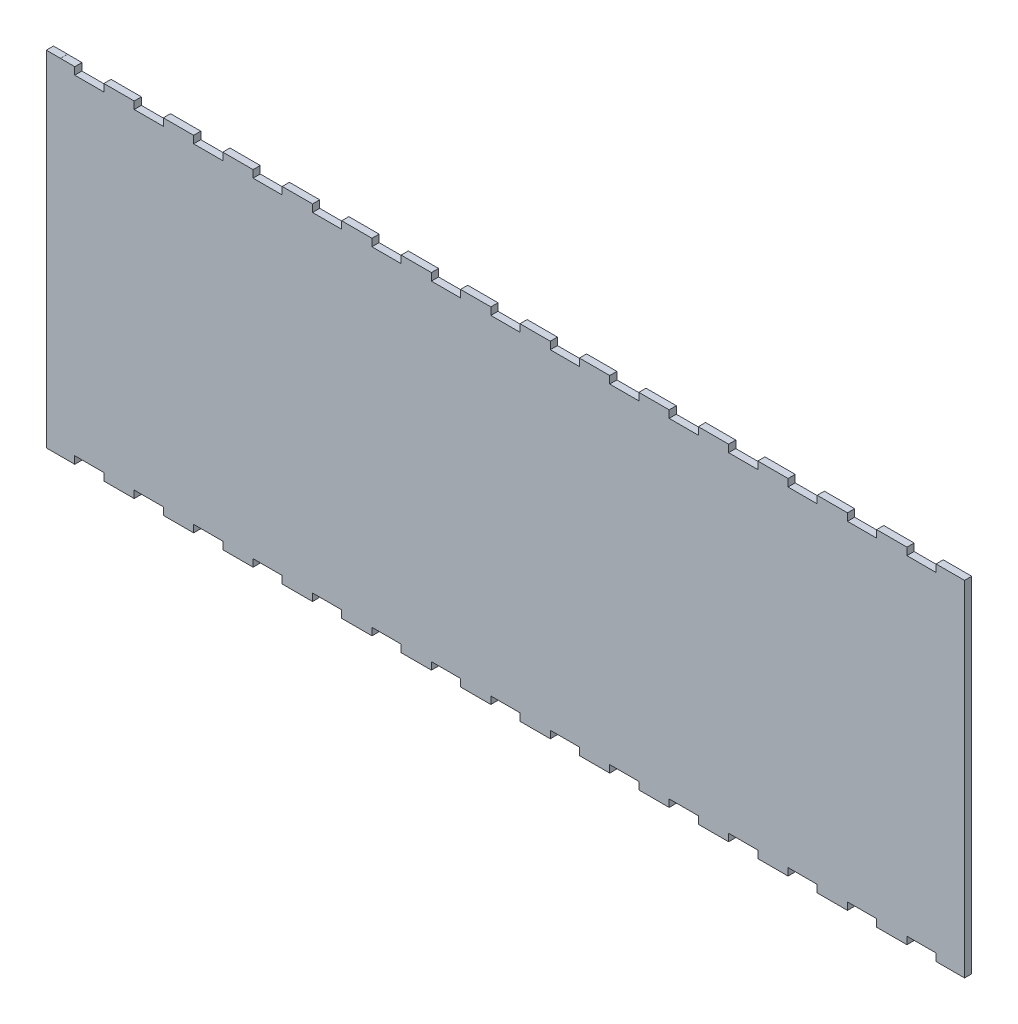
from build123d import *

# Parameters (mm, degrees)
BOSS_EXTRUDE2_DEPTH = 3.175


with BuildPart() as part:
    # Sketch1 → Boss-Extrude2 (new body)
    with BuildSketch(Plane.XY):
        Polygon((393.8, 152.4), (393.8, 149.125), (380.9, 149.125), (380.9, 152.4), (367.492857143, 152.4), (367.492857143, 149.125), (354.592857143, 149.125), (354.592857143, 152.4), (341.185714286, 152.4), (341.185714286, 149.125), (328.285714286, 149.125), (328.285714286, 152.4), (314.878571429, 152.4), (314.878571429, 149.125), (301.978571429, 149.125), (301.978571429, 152.4), (288.571428571, 152.4), (288.571428571, 149.125), (275.671428571, 149.125), (275.671428571, 152.4), (262.264285714, 152.4), (262.264285714, 149.125), (249.364285714, 149.125), (249.364285714, 152.4), (235.957142857, 152.4), (235.957142857, 149.125), (223.057142857, 149.125), (223.057142857, 152.4), (209.65, 152.4), (209.65, 149.125), (196.75, 149.125), (196.75, 152.4), (183.342857143, 152.4), (183.342857143, 149.125), (170.442857143, 149.125), (170.442857143, 152.4), (157.035714286, 152.4), (157.035714286, 149.125), (144.135714286, 149.125), (144.135714286, 152.4), (130.728571429, 152.4), (130.728571429, 149.125), (117.828571429, 149.125), (117.828571429, 152.4), (104.421428571, 152.4), (104.421428571, 149.125), (91.521428571, 149.125), (91.521428571, 152.4), (78.114285714, 152.4), (78.114285714, 149.125), (65.214285714, 149.125), (65.214285714, 152.4), (51.807142857, 152.4), (51.807142857, 149.125), (38.907142857, 149.125), (38.907142857, 152.4), (25.5, 152.4), (25.5, 149.125), (12.6, 149.125), (12.6, 152.4), (6.2500002, 152.4), (6.2500002, 152.4254), (0, 152.4254), (0, -0.0254), (12.6000002, -0.0254), (12.6, 3.275), (25.5, 3.275), (25.5, 0), (38.907142857, 0), (38.907142857, 3.275), (51.807142857, 3.275), (51.807142857, 0), (65.214285714, 0), (65.214285714, 3.275), (78.114285714, 3.275), (78.114285714, 0), (91.521428571, 0), (91.521428571, 3.275), (104.421428571, 3.275), (104.421428571, 0), (117.828571429, 0), (117.828571429, 3.275), (130.728571429, 3.275), (130.728571429, 0), (144.135714286, 0), (144.135714286, 3.275), (157.035714286, 3.275), (157.035714286, 0), (170.442857143, 0), (170.442857143, 3.275), (183.342857143, 3.275), (183.342857143, 0), (196.75, 0), (196.75, 3.275), (209.65, 3.275), (209.65, 0), (223.057142857, 0), (223.057142857, 3.275), (235.957142857, 3.275), (235.957142857, 0), (249.364285714, 0), (249.364285714, 3.275), (262.264285714, 3.275), (262.264285714, 0), (275.671428571, 0), (275.671428571, 3.275), (288.571428571, 3.275), (288.571428571, 0), (301.978571429, 0), (301.978571429, 3.275), (314.878571429, 3.275), (314.878571429, 0), (328.285714286, 0), (328.285714286, 3.275), (341.185714286, 3.275), (341.185714286, 0), (354.592857143, 0), (354.592857143, 3.275), (367.492857143, 3.275), (367.492857143, 0), (380.9, 0), (380.9, 3.275), (393.8, 3.275), (393.8, 0), (406.4, 0), (406.4, 152.4), align=None)
    extrude(amount=BOSS_EXTRUDE2_DEPTH)


solid = part.part
